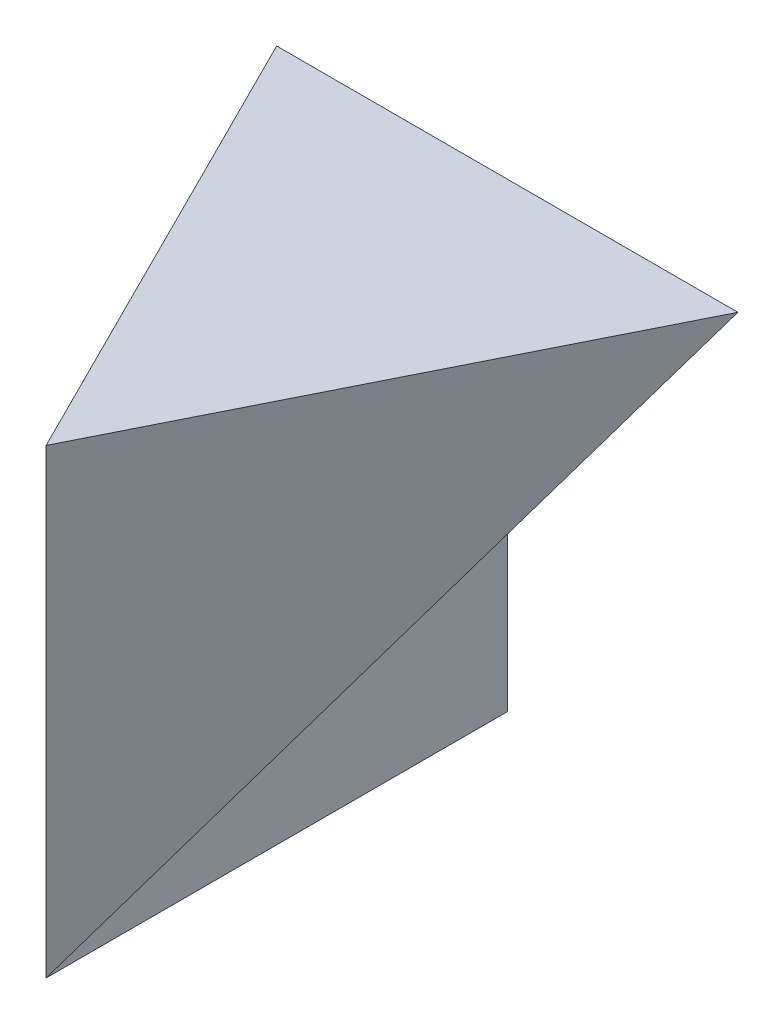
from build123d import *

# Parameters (mm, degrees)
SKETCH1_W           = 40
SKETCH1_H           = 40
BOSS_EXTRUDE1_DEPTH = 40
CUT_EXTRUDE1_DEPTH  = 20
CUT_EXTRUDE2_DEPTH  = 60
CUT_EXTRUDE3_DEPTH  = 60


with BuildPart() as part:
    # Sketch1 → Boss-Extrude1 (new body)
    with BuildSketch(Plane(origin=(0, 0, 0), x_dir=(0, 0, -1), z_dir=(1, 0, 0))):
        with Locations((20, 20)):
            Rectangle(SKETCH1_W, SKETCH1_H)
    extrude(amount=BOSS_EXTRUDE1_DEPTH)

    # Sketch2 → Cut-Extrude1 (cut)
    with BuildSketch(Plane(origin=(40, 0, 0), x_dir=(0, 0, -1), z_dir=(1, 0, 0))):
        Polygon((0, 0), (40, 40), (40, 0), align=None)
    extrude(amount=-CUT_EXTRUDE1_DEPTH, mode=Mode.SUBTRACT)

    # Sketch3 → Cut-Extrude2 (cut)
    with BuildSketch(Plane.XY):
        Polygon((0, 0), (20, 0), (0, 40), align=None)
        Polygon((40, 40), (20, 0), (40, 0), align=None)
    extrude(amount=-CUT_EXTRUDE2_DEPTH, mode=Mode.SUBTRACT)

    # Sketch4 → Cut-Extrude3 (cut)
    with BuildSketch(Plane(origin=(0, 0, 0), x_dir=(1, 0, 0), z_dir=(0, 1, 0))):
        Polygon((0, 0), (20, 0), (0, 40), align=None)
        Polygon((40, 40), (20, 0), (40, 0), align=None)
    extrude(amount=CUT_EXTRUDE3_DEPTH, mode=Mode.SUBTRACT)


solid = part.part
